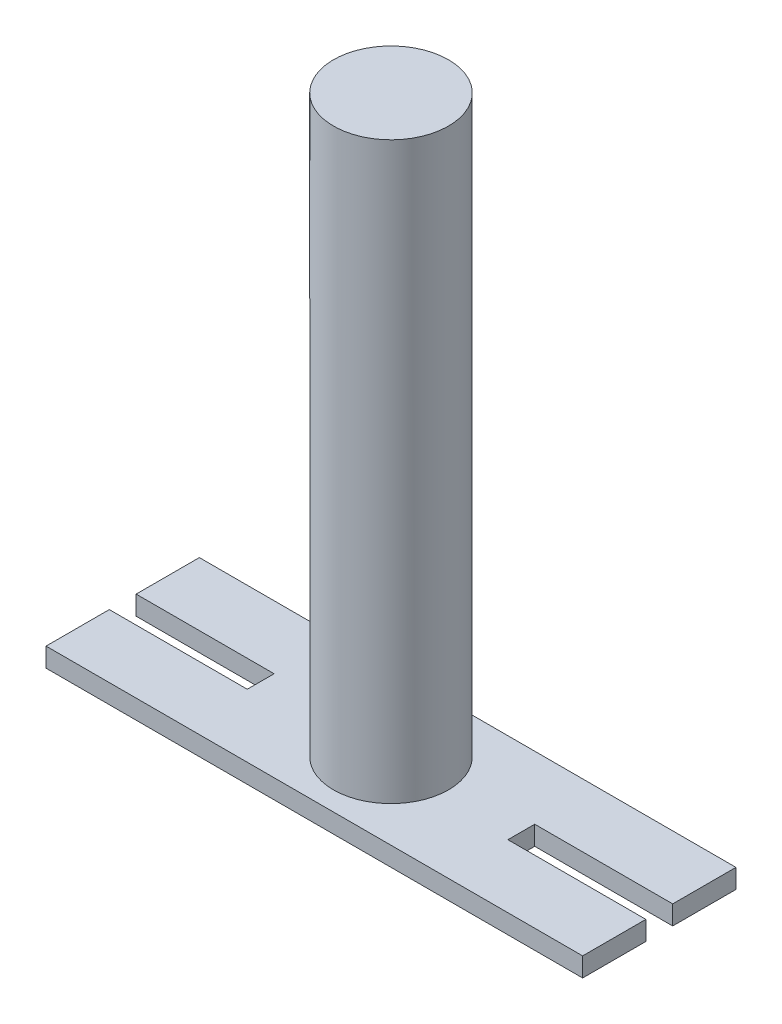
from build123d import *

# Parameters (mm, degrees)
SKETCH2_R           = 254
BOSS_EXTRUDE1_DEPTH = 127


with BuildPart() as part:
    # Sketch2 → Boss-Extrude1 (new body)
    with BuildSketch(Plane(origin=(0, 0, 0), x_dir=(1, 0, 0), z_dir=(0, 1, 0))):
        Polygon((1778, 508), (-1778, 508), (-1778, 88.9), (-863.6, 88.9), (-863.6, -88.9), (-1778, -88.9), (-1778, -508), (1778, -508), (1778, -88.9), (863.6, -88.9), (863.6, 88.9), (1778, 88.9), align=None)
        Circle(SKETCH2_R, mode=Mode.SUBTRACT)
    extrude(amount=BOSS_EXTRUDE1_DEPTH)

    # Sketch3 → Revolve1 (revolve)
    with BuildSketch(Plane.XY):
        Polygon((0, 3937), (381, 3937), (381, 127), (254, 127), (254, 3810), (0, 3810), align=None)
    revolve(axis=Axis((0, 0, 0), (0, 1, 0)))


solid = part.part
